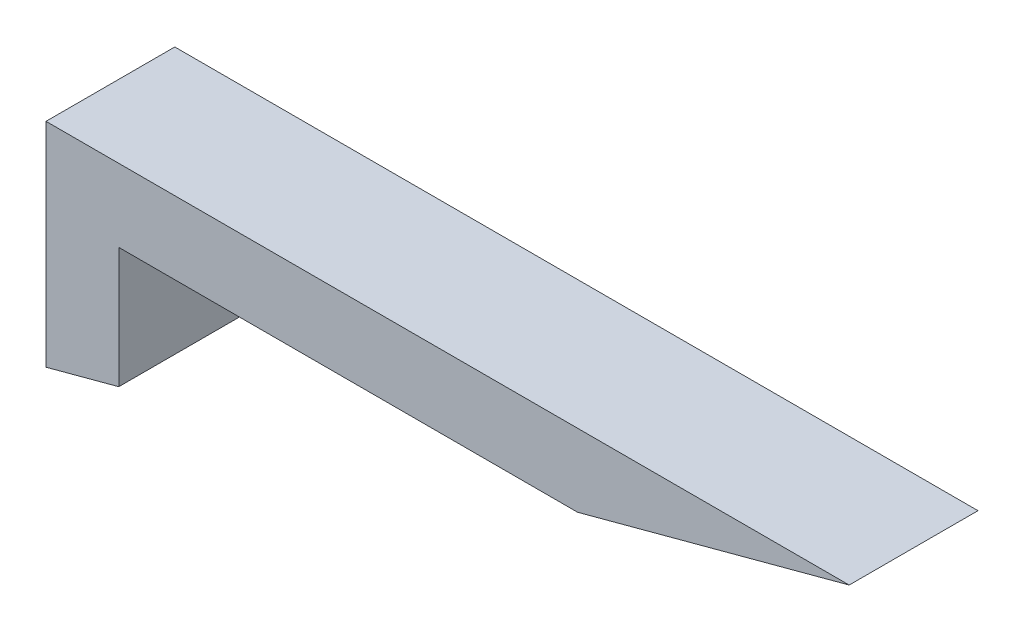
from build123d import *

# Parameters (mm, degrees)
SKETCH1_W           = 25.4
SKETCH1_H           = 25.4
BOSS_EXTRUDE1_DEPTH = 44.958


with BuildPart() as part:
    # Sketch1 → Boss-Extrude1 (new body)
    with BuildSketch(Plane.XY):
        Polygon((-12.7, 0), (12.7, 6.805909488), (12.7, 48.930936062), (-12.7, 48.930936062), align=None)
        with Locations((0, 61.630936062)):
            Rectangle(SKETCH1_W, SKETCH1_H)
        Polygon((12.7, 74.330936062), (12.7, 48.930936062), (172.856591106, 48.930936062), (267.650681618, 74.330936062), align=None)
    extrude(amount=BOSS_EXTRUDE1_DEPTH)


solid = part.part
